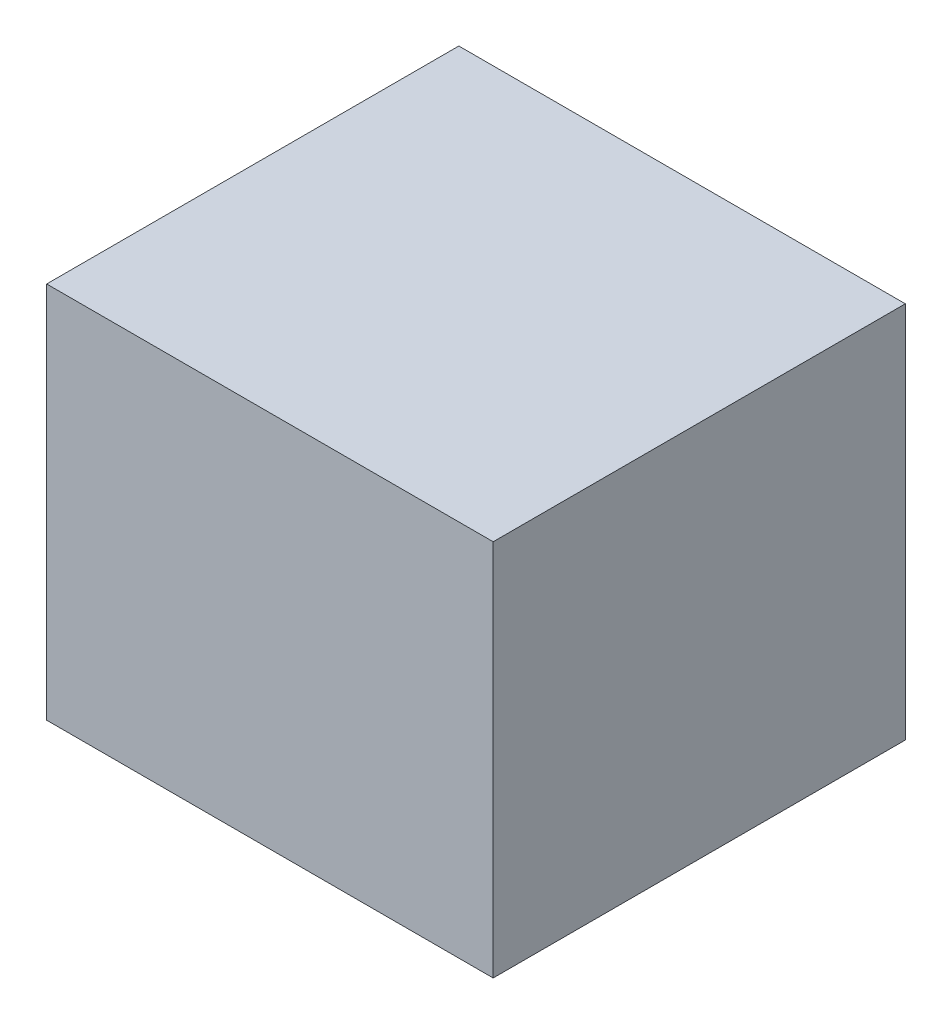
from build123d import *

# Parameters (mm, degrees)
SKETCH1_W           = 1651
SKETCH1_H           = 1524
BOSS_EXTRUDE1_DEPTH = 1397


with BuildPart() as part:
    # Sketch1 → Boss-Extrude1 (new body)
    with BuildSketch(Plane(origin=(0, 0, 0), x_dir=(1, 0, 0), z_dir=(0, 1, 0))):
        Rectangle(SKETCH1_W, SKETCH1_H)
    extrude(amount=BOSS_EXTRUDE1_DEPTH)


solid = part.part
